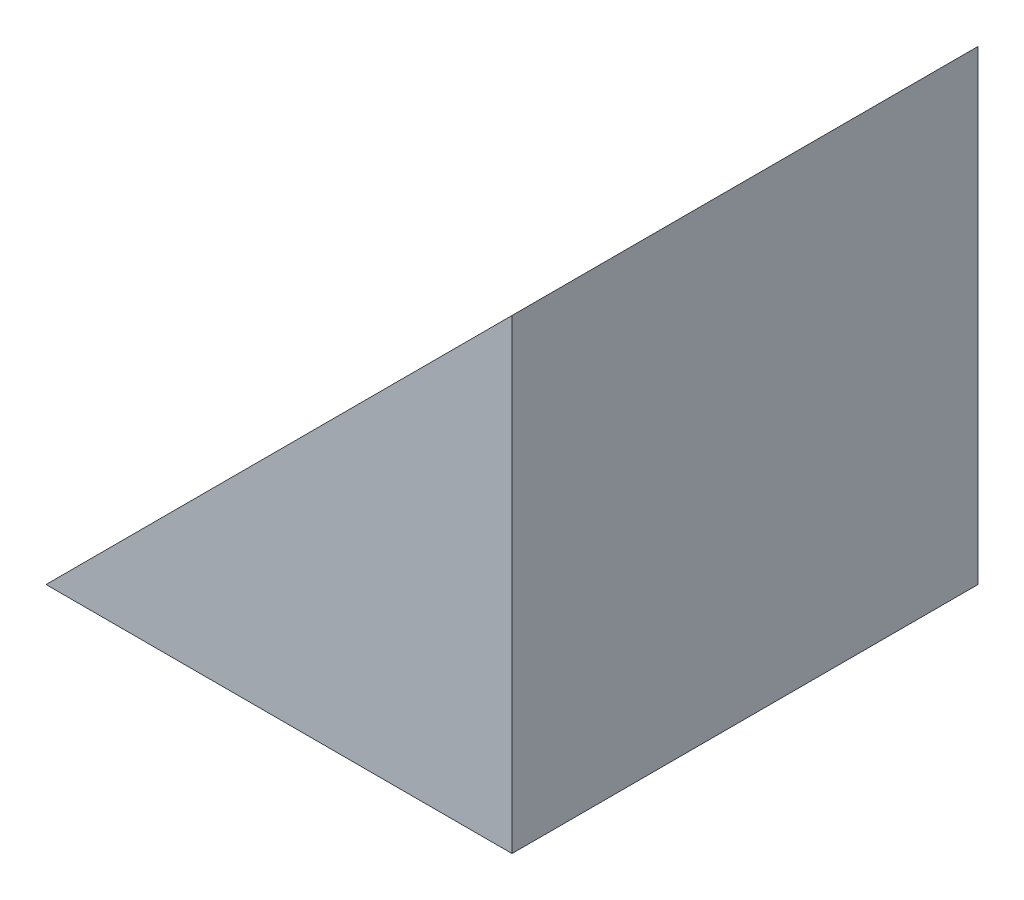
from build123d import *

# Parameters (mm, degrees)
EXTRUDE_1_DEPTH = 10


with BuildPart() as part:
    # 草图1 → 凸台-拉伸1 (new body)
    with BuildSketch(Plane.XY):
        Polygon((34.942812742, 26.555814048), (34.942812742, 36.555814048), (24.942812742, 26.555814048), align=None)
    extrude(amount=EXTRUDE_1_DEPTH)


solid = part.part
